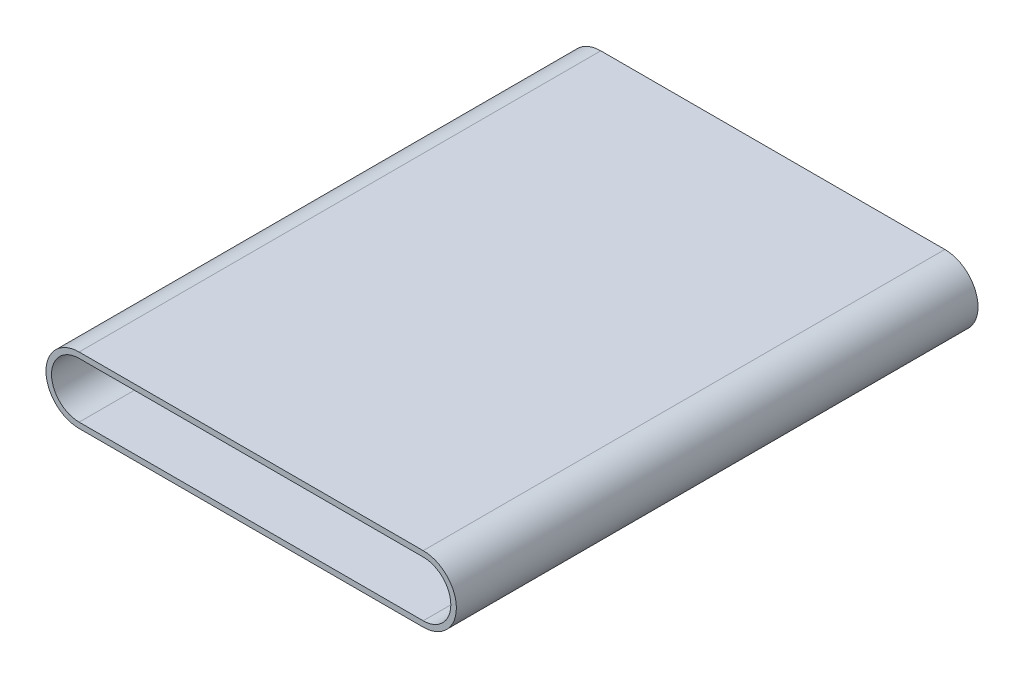
from build123d import *

# Parameters (mm, degrees)
SKETCH3_W = 470
SKETCH3_H = 5


with BuildPart() as part:
    # Sweep1: sweep along a path in Sketch2
    with BuildLine(Plane.XY) as sweep1_path:
        Line((0, -24.875), (-310, -24.875))
        ThreePointArc((-310, -24.875), (-334.875, 0), (-310, 24.875))
        Line((-310, 24.875), (0, 24.875))
        ThreePointArc((0, 24.875), (24.875, 0), (0, -24.875))
    # Sketch3 → Sweep1 (sweep)
    with BuildSketch(Plane(origin=(0, 0, 0), x_dir=(0, 0, -1), z_dir=(1, 0, 0))):
        with Locations((0, 27.375)):
            Rectangle(SKETCH3_W, SKETCH3_H)
    sweep(path=sweep1_path.line)


solid = part.part
